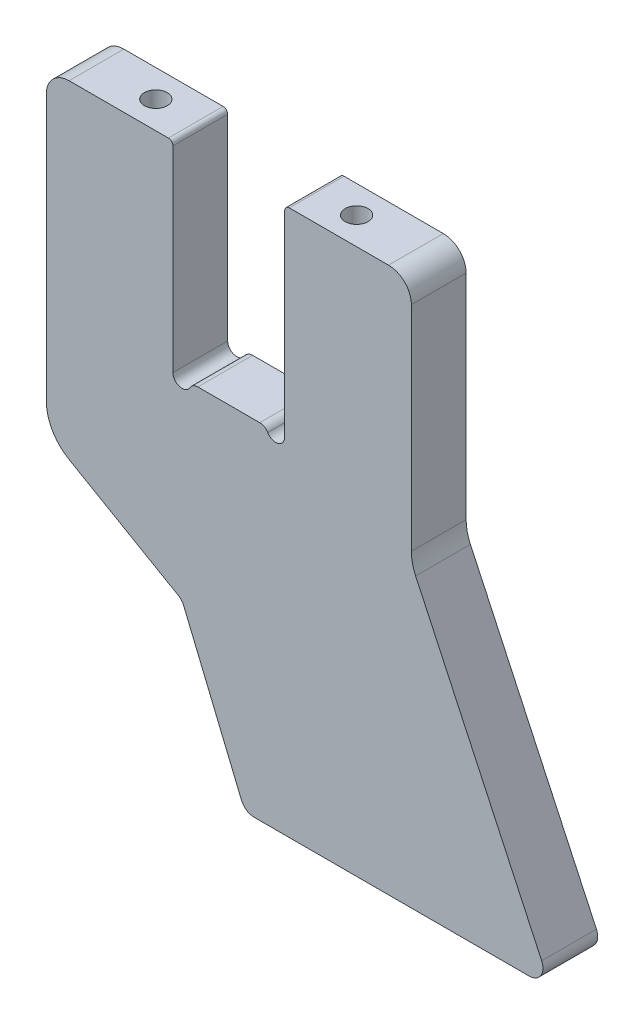
from build123d import *

# Parameters (mm, degrees)
EXTRUDE1_DEPTH   = 12
F_2_STK_M6_D     = 5
F_2_STK_M6_DEPTH = 14
F_2_STK_M6_TIP   = 1.502151548


with BuildPart() as part:
    # Sketch1 → Extrude1 (new body)
    with BuildSketch(Plane.XY):
        with BuildLine():
            Line((-6.785898385, 0), (6.785898385, 0))
            ThreePointArc((6.785898385, 0), (7.785898385, -0.267949192), (8.517949192, -1))
            ThreePointArc((8.517949192, -1), (10.76763809, -1.931851653), (12.25, 0))
            Line((12.25, 0), (12.25, 43))
            ThreePointArc((12.25, 43), (12.542893219, 43.707106781), (13.25, 44))
            Line((13.25, 44), (35, 44))
            ThreePointArc((35, 44), (38.535533906, 42.535533906), (40, 39))
            Line((40, 39), (40, -7.783053374))
            ThreePointArc((40, -7.783053374), (40.237039929, -9.947449513), (40.93692213, -12.009235991))
            Line((40.93692213, -12.009235991), (68.553018239, -71.232145215))
            ThreePointArc((68.553018239, -71.232145215), (68.364269215, -74.111898825), (65.834094878, -75.5))
            Line((65.834094878, -75.5), (5.547687523, -75.5))
            ThreePointArc((5.547687523, -75.5), (3.880976824, -74.994408837), (2.776048925, -73.648050297))
            Line((2.776048925, -73.648050297), (-9.873472677, -43.109403687))
            ThreePointArc((-9.873472677, -43.109403687), (-10.389591852, -42.279416539), (-11.145111274, -41.659377773))
            Line((-11.145111274, -41.659377773), (-35, -27.886751346))
            ThreePointArc((-35, -27.886751346), (-38.660254038, -24.226497308), (-40, -19.226497308))
            Line((-40, -19.226497308), (-40, 39))
            ThreePointArc((-40, 39), (-38.535533906, 42.535533906), (-35, 44))
            Line((-35, 44), (-13.25, 44))
            ThreePointArc((-13.25, 44), (-12.542893219, 43.707106781), (-12.25, 43))
            Line((-12.25, 43), (-12.25, 0))
            ThreePointArc((-12.25, 0), (-10.76763809, -1.931851653), (-8.517949192, -1))
            ThreePointArc((-8.517949192, -1), (-7.785898385, -0.267949192), (-6.785898385, 0))
        make_face()
    extrude(amount=EXTRUDE1_DEPTH)

    # 2 stk M6
    with Locations(Plane(origin=(0, 44, 0), x_dir=(-1, 0, 0), z_dir=(0, 1, 0))):
        with Locations((-22, 6), (22, 6)):
            Hole(F_2_STK_M6_D / 2, depth=F_2_STK_M6_DEPTH)
            with Locations((0, 0, -(F_2_STK_M6_DEPTH + F_2_STK_M6_TIP / 2))):  # 118° drill point
                Cone(0, F_2_STK_M6_D / 2, F_2_STK_M6_TIP, mode=Mode.SUBTRACT)


solid = part.part
